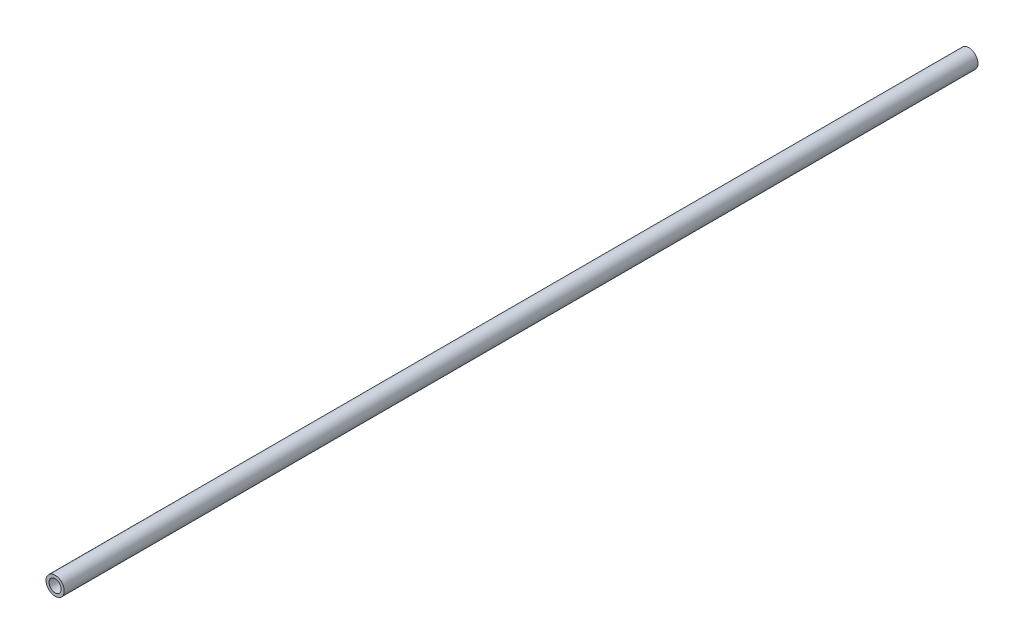
from build123d import *

# Parameters (mm, degrees)
SKETCH1_R           = 7.62
SKETCH1_R_2         = 5.08
BOSS_EXTRUDE1_DEPTH = 762


with BuildPart() as part:
    # Sketch1 → Boss-Extrude1 (new body)
    with BuildSketch(Plane.XY):
        Circle(SKETCH1_R)
        Circle(SKETCH1_R_2, mode=Mode.SUBTRACT)
    extrude(amount=BOSS_EXTRUDE1_DEPTH)


solid = part.part
